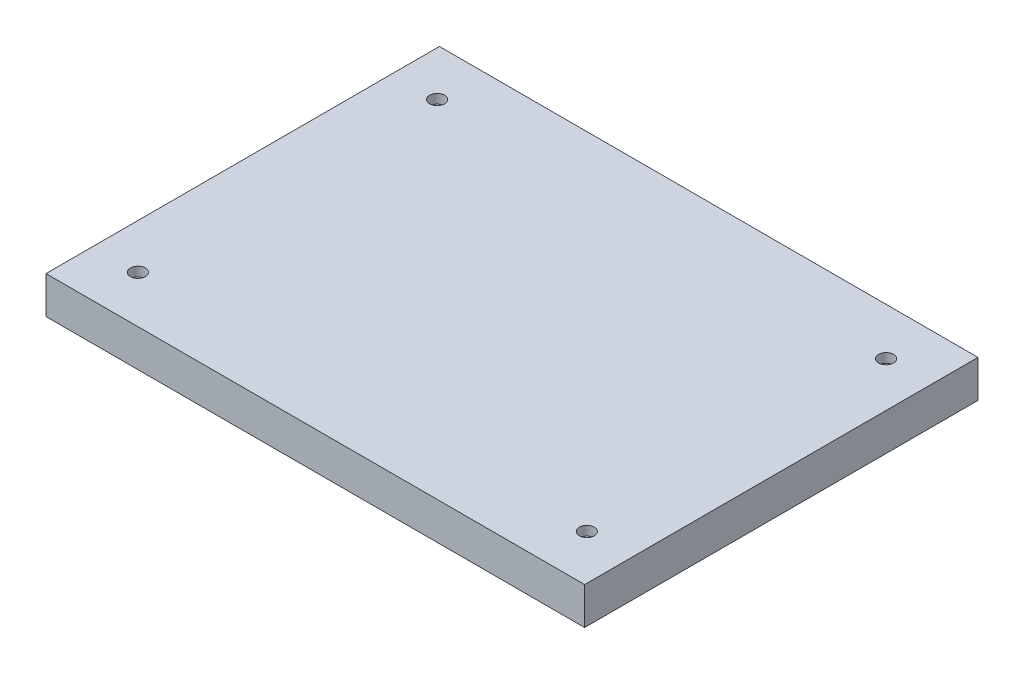
from build123d import *

# Parameters (mm, degrees)
SKETCH1_W           = 359.918
SKETCH1_H           = 262.89
BOSS_EXTRUDE1_DEPTH = 12.446
SKETCH5_R           = 5
CUT_EXTRUDE1_DEPTH  = 6.223


with BuildPart() as part:
    # Sketch1 → Boss-Extrude1 (new body, symmetric)
    with BuildSketch(Plane(origin=(0, 0, 0), x_dir=(1, 0, 0), z_dir=(0, 1, 0))):
        Rectangle(SKETCH1_W, SKETCH1_H)
    extrude(amount=BOSS_EXTRUDE1_DEPTH, both=True)

    # Sketch5 → Cut-Extrude1 (cut)
    with BuildSketch(Plane(origin=(0, 12.446, 0), x_dir=(1, 0, 0), z_dir=(0, 1, 0))):
        with Locations((-150, 100)):
            Circle(SKETCH5_R)
        with Locations((150, 100)):
            Circle(SKETCH5_R)
        with Locations((150, -100)):
            Circle(SKETCH5_R)
        with Locations((-150, -100)):
            Circle(SKETCH5_R)
    extrude(amount=-CUT_EXTRUDE1_DEPTH, mode=Mode.SUBTRACT)


solid = part.part
